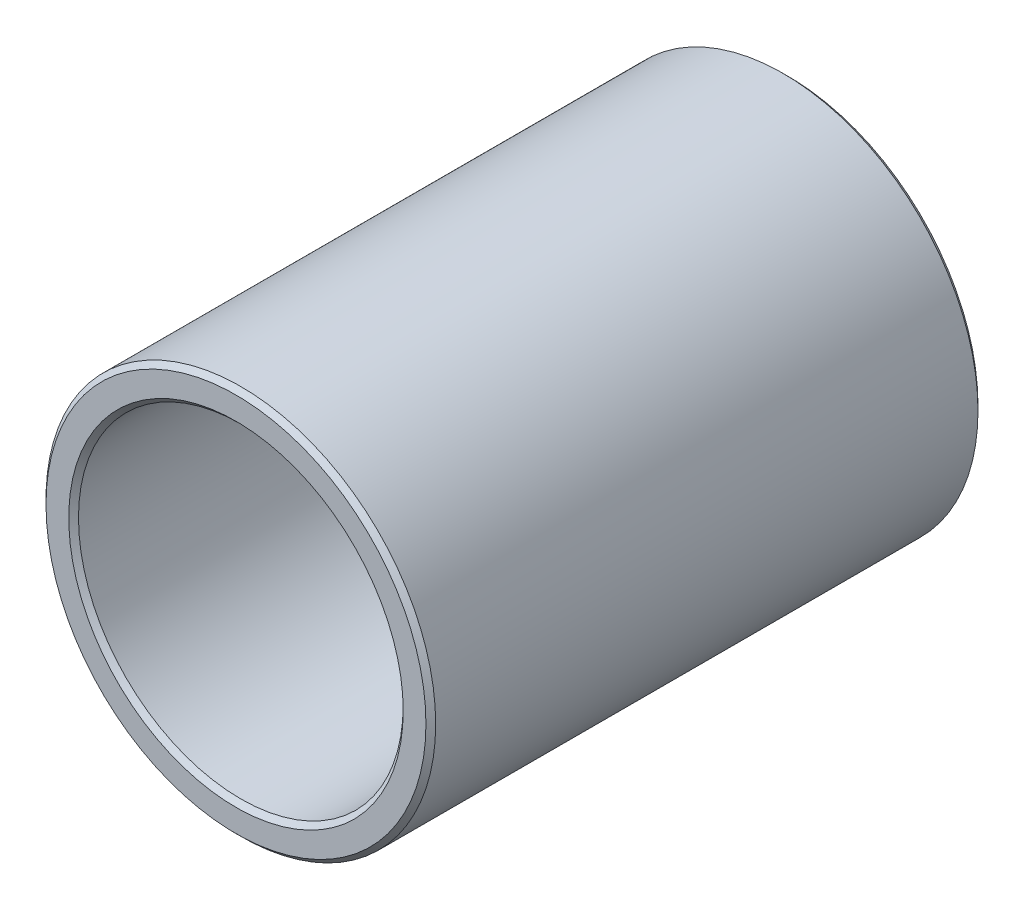
from build123d import *

# Parameters (mm, degrees)
SCHIZZO1_R                   = 12
SCHIZZO1_R_2                 = 10
ESTRUSIONE_ESTRUSIONE1_DEPTH = 34
SMUSSO1_SIZE                 = 0.3


with BuildPart() as part:
    # Schizzo1 → Estrusione-Estrusione1 (new body)
    with BuildSketch(Plane.XY):
        Circle(SCHIZZO1_R)
        Circle(SCHIZZO1_R_2, mode=Mode.SUBTRACT)
    extrude(amount=ESTRUSIONE_ESTRUSIONE1_DEPTH)

    # Smusso1
    smusso1_edges = [part.edges().sort_by_distance(p)[0] for p in [
        (-12, 0, 0),
        (-12, 0, 34),
        (-10, 0, 0),
        (-10, 0, 34),
    ]]
    chamfer(smusso1_edges, length=SMUSSO1_SIZE)


solid = part.part
